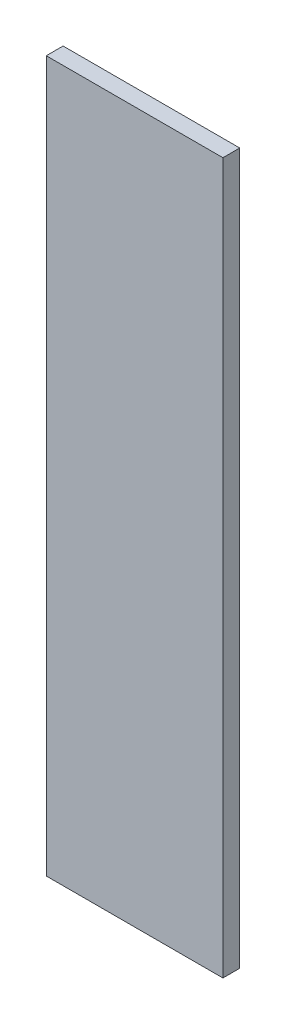
from build123d import *

# Parameters (mm, degrees)
SKETCH1_W           = 189
SKETCH1_H           = 760
BOSS_EXTRUDE1_DEPTH = 18


with BuildPart() as part:
    # Sketch1 → Boss-Extrude1 (new body)
    with BuildSketch(Plane.XY):
        Rectangle(SKETCH1_W, SKETCH1_H)
    extrude(amount=BOSS_EXTRUDE1_DEPTH)


solid = part.part
